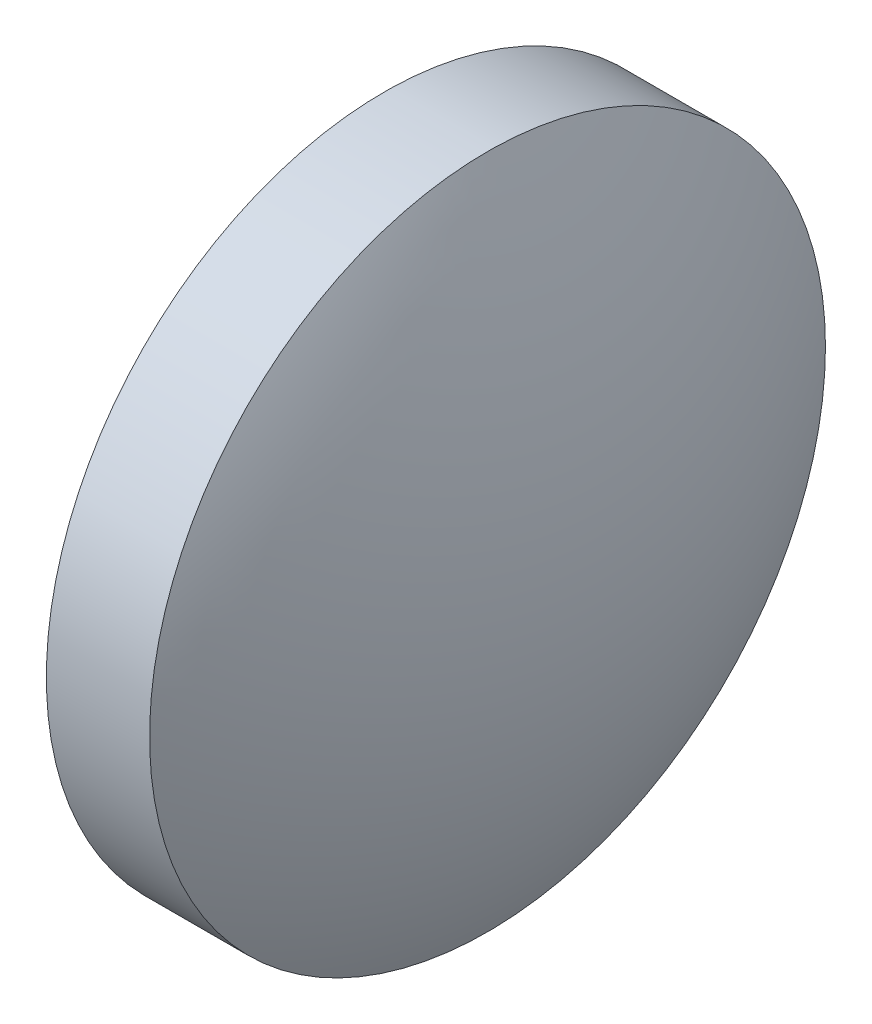
from build123d import *

# Parameters (mm, degrees)
SKETCH1_R           = 8.185
BOSS_EXTRUDE1_DEPTH = 2.5
DOME1_FACE_RADIUS   = 8.185
DOME1_HEIGHT        = 2


with BuildPart() as part:
    # Sketch1 → Boss-Extrude1 (new body)
    with BuildSketch(Plane(origin=(0, 0, 0), x_dir=(0, 0, -1), z_dir=(1, 0, 0))):
        Circle(SKETCH1_R)
    extrude(amount=BOSS_EXTRUDE1_DEPTH)

    # Dome1: a dome of height H over a round flat face of radius A is a cap of a sphere of radius (A * A + H * H) / (2 * H)
    dome1_r = (DOME1_FACE_RADIUS * DOME1_FACE_RADIUS + DOME1_HEIGHT * DOME1_HEIGHT) / (2 * DOME1_HEIGHT)
    dome1_base = Plane((2.5, 0, 0), z_dir=(1, 0, 0))
    with Locations(dome1_base.offset(DOME1_HEIGHT - dome1_r)):
        dome1_ball = Sphere(dome1_r, mode=Mode.PRIVATE)
    add(split(dome1_ball, bisect_by=dome1_base, keep=Keep.TOP, mode=Mode.PRIVATE))


solid = part.part
